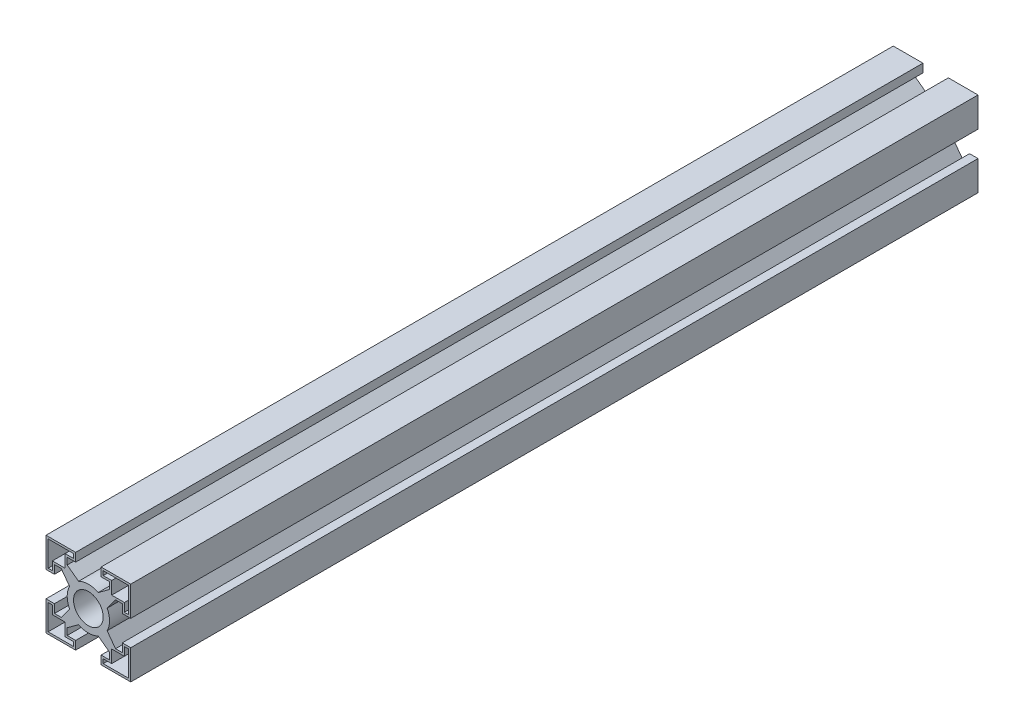
from build123d import *

# Parameters (mm, degrees)
ESQUISSE1_R        = 1.75
BOSS_EXTRU_1_DEPTH = 100


with BuildPart() as part:
    # Esquisse1 → Boss.-Extru.1 (new body)
    with BuildSketch(Plane.XY):
        with BuildLine():
            Line((-1.5, 5), (-5, 5))
            Line((-5, 5), (-5, 1.5))
            Line((-5, 1.5), (-4, 1.5))
            Line((-4, 1.5), (-4, 2.5))
            Line((-4, 2.5), (-3.207106781, 2.5))
            Line((-3.207106781, 2.5), (-2.216672281, 1.15601211))
            ThreePointArc((-2.216672281, 1.15601211), (-2.5, 0), (-2.216672281, -1.15601211))
            Line((-2.216672281, -1.15601211), (-3.207106781, -2.5))
            Line((-3.207106781, -2.5), (-4, -2.5))
            Line((-4, -2.5), (-4, -1.5))
            Line((-4, -1.5), (-5, -1.5))
            Line((-5, -1.5), (-5, -5))
            Line((-5, -5), (-1.5, -5))
            Line((-1.5, -5), (-1.5, -4))
            Line((-1.5, -4), (-2.5, -4))
            Line((-2.5, -4), (-2.5, -3.207106781))
            Line((-2.5, -3.207106781), (-1.15601211, -2.216672281))
            ThreePointArc((-1.15601211, -2.216672281), (0, -2.5), (1.15601211, -2.216672281))
            Line((1.15601211, -2.216672281), (2.5, -3.207106781))
            Line((2.5, -3.207106781), (2.5, -4))
            Line((2.5, -4), (1.5, -4))
            Line((1.5, -4), (1.5, -5))
            Line((1.5, -5), (5, -5))
            Line((5, -5), (5, -1.5))
            Line((5, -1.5), (4, -1.5))
            Line((4, -1.5), (4, -2.5))
            Line((4, -2.5), (3.207106781, -2.5))
            Line((3.207106781, -2.5), (2.216672281, -1.15601211))
            ThreePointArc((2.216672281, -1.15601211), (2.5, 0), (2.216672281, 1.15601211))
            Line((2.216672281, 1.15601211), (3.207106781, 2.5))
            Line((3.207106781, 2.5), (4, 2.5))
            Line((4, 2.5), (4, 1.5))
            Line((4, 1.5), (5, 1.5))
            Line((5, 1.5), (5, 5))
            Line((5, 5), (1.5, 5))
            Line((1.5, 5), (1.5, 4))
            Line((1.5, 4), (2.5, 4))
            Line((2.5, 4), (2.5, 3.207106781))
            Line((2.5, 3.207106781), (1.15601211, 2.216672281))
            ThreePointArc((1.15601211, 2.216672281), (0, 2.5), (-1.15601211, 2.216672281))
            Line((-1.15601211, 2.216672281), (-2.5, 3.207106781))
            Line((-2.5, 3.207106781), (-2.5, 4))
            Line((-2.5, 4), (-1.5, 4))
            Line((-1.5, 4), (-1.5, 5))
        make_face()
        Polygon((-4.75, 1.75), (-4.75, 4.75), (-1.75, 4.75), (-1.75, 4.25), (-2.75, 4.25), (-2.75, 2.75), (-4.25, 2.75), (-4.25, 1.75), align=None, mode=Mode.SUBTRACT)
        Circle(ESQUISSE1_R, mode=Mode.SUBTRACT)
        Polygon((-4.75, -4.75), (-4.75, -1.75), (-4.25, -1.75), (-4.25, -2.75), (-2.75, -2.75), (-2.75, -4.25), (-1.75, -4.25), (-1.75, -4.75), align=None, mode=Mode.SUBTRACT)
        Polygon((4.75, 4.75), (4.75, 1.75), (4.25, 1.75), (4.25, 2.75), (2.75, 2.75), (2.75, 4.25), (1.75, 4.25), (1.75, 4.75), align=None, mode=Mode.SUBTRACT)
        Polygon((4.75, -4.75), (1.75, -4.75), (1.75, -4.25), (2.75, -4.25), (2.75, -2.75), (4.25, -2.75), (4.25, -1.75), (4.75, -1.75), align=None, mode=Mode.SUBTRACT)
    extrude(amount=BOSS_EXTRU_1_DEPTH)


solid = part.part
